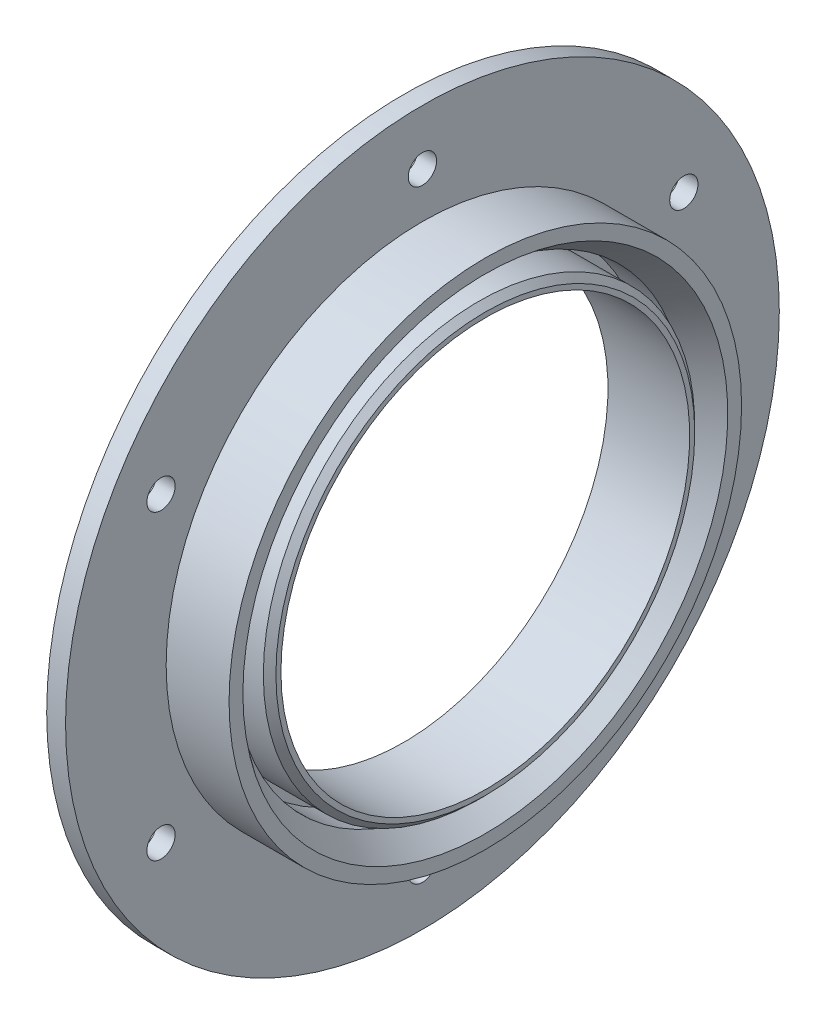
from build123d import *

# Parameters (mm, degrees)
CHAMFER1_SIZE      = 4
CHAMFER1_SIZE2     = 2.800830153
CHAMFER2_SIZE      = 1
SKETCH2_R          = 2.25
CUT_EXTRUDE1_DEPTH = 10
CIRPATTERN1_COUNT  = 6


with BuildPart() as part:
    # Sketch1 → Revolve1 (revolve)
    with BuildSketch(Plane.XY):
        Polygon((0, 32.5), (13, 32.5), (13, 34.3), (3, 34.3), (3, 35.75), (13, 35.75), (13, 40.75), (3, 40.75), (3, 56.75), (0, 56.75), align=None)
    revolve(axis=Axis((0, 0, 0), (1, 0, 0)))

    # Chamfer1
    chamfer1_edges = [part.edges().sort_by_distance(p)[0] for p in [
        (13, -35.75, 0),
    ]]
    chamfer1_side = [part.faces().sort_by_distance(p)[0] for p in [
        (8, -35.75, 0),
    ]]
    chamfer(chamfer1_edges, length=CHAMFER1_SIZE, length2=CHAMFER1_SIZE2, reference=chamfer1_side[0])

    # Chamfer2
    chamfer2_edges = [part.edges().sort_by_distance(p)[0] for p in [
        (13, -34.3, 0),
    ]]
    chamfer(chamfer2_edges, length=CHAMFER2_SIZE)

    # Sketch2 → Cut-Extrude1 (cut)
    with BuildSketch(Plane(origin=(3, 0, 0), x_dir=(0, 0, -1), z_dir=(1, 0, 0))):
        with Locations((0, 48)):
            Circle(SKETCH2_R)
    cut_extrude1 = extrude(amount=-CUT_EXTRUDE1_DEPTH, mode=Mode.SUBTRACT)

    # CirPattern1: Cut-Extrude1 ×6 about axis
    cirpattern1_axis = Axis((0, 0, 0), (1, 0, 0))
    for i in range(1, CIRPATTERN1_COUNT):
        add(cut_extrude1.rotate(cirpattern1_axis, i * 360 / CIRPATTERN1_COUNT), mode=Mode.SUBTRACT)


solid = part.part
